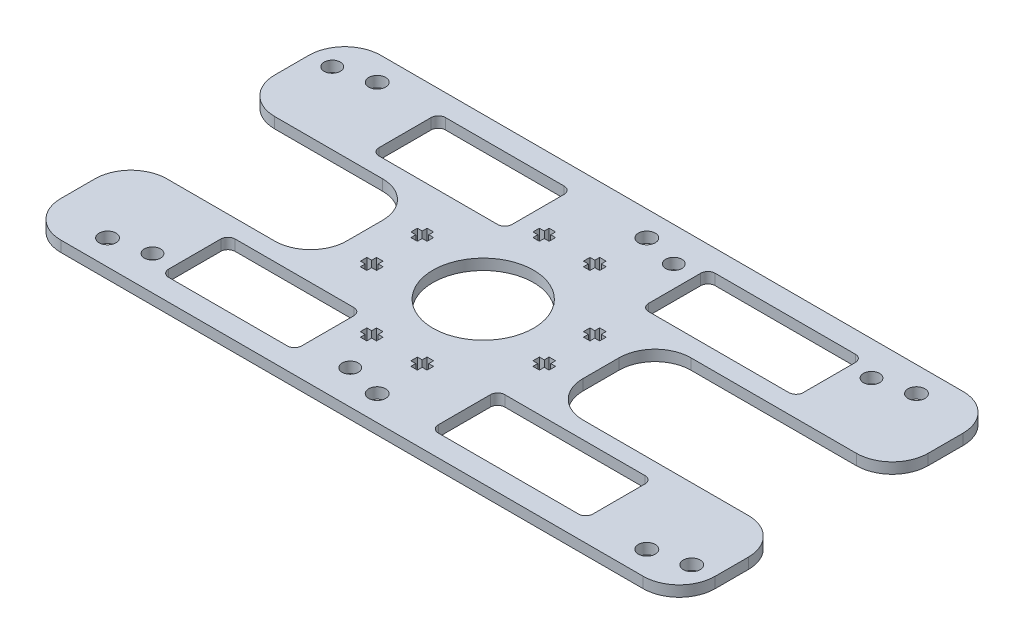
from build123d import *

# Parameters (mm, degrees)
SKETCH1_R           = 14
SKETCH1_R_2         = 2.35
BOSS_EXTRUDE1_DEPTH = 3
CUT_EXTRUDE1_DEPTH  = 104.545719252
FILLET1_R           = 10
SKETCH4_R           = 2.35
SKETCH4_R_2         = 2.25
CUT_EXTRUDE2_DEPTH  = 10
CUT_EXTRUDE3_DEPTH  = 10


with BuildPart() as part:
    # Sketch1 → Boss-Extrude1 (new body)
    with BuildSketch(Plane(origin=(0, 0, 0), x_dir=(1, 0, 0), z_dir=(0, 1, 0))):
        Polygon((24.685193035, -44.266394733), (93.336062351, -44.266394733), (93.336062351, -15), (27.336052671, -15), (27.336052671, 15), (93.336062351, 15), (93.336062351, 44.733605267), (24.683748509, 44.733605267), (-88.663937649, 44.733605267), (-88.663937649, 15.233605267), (-38.663937649, 15.233605267), (-38.663937649, -14.766394733), (-88.663937649, -14.766394733), (-88.663937649, -44.266394733), align=None)
        with Locations((-5.663947329, 0.233605267)):
            Circle(SKETCH1_R, mode=Mode.SUBTRACT)
        with Locations((-72.663947329, -37.266394733)):
            Circle(SKETCH1_R_2, mode=Mode.SUBTRACT)
        with Locations((2.336052671, -37.266394733)):
            Circle(SKETCH1_R_2, mode=Mode.SUBTRACT)
        with Locations((77.336052671, -37.266394733)):
            Circle(SKETCH1_R_2, mode=Mode.SUBTRACT)
        with Locations((77.336052671, 37.733605267)):
            Circle(SKETCH1_R_2, mode=Mode.SUBTRACT)
        with Locations((2.336052671, 37.733605267)):
            Circle(SKETCH1_R_2, mode=Mode.SUBTRACT)
        with Locations((-72.663947329, 37.733605267)):
            Circle(SKETCH1_R_2, mode=Mode.SUBTRACT)
    extrude(amount=BOSS_EXTRUDE1_DEPTH)

    # Sketch3 → Cut-Extrude1 (cut, through all)
    with BuildSketch(Plane(origin=(0, 3, 0), x_dir=(1, 0, 0), z_dir=(0, 1, 0))):
        Polygon((20.586052671, -7.695831984), (20.586052671, -5.895831984), (19.236052671, -5.895831984), (19.236052671, -4.545831984), (17.436052671, -4.545831984), (17.436052671, -5.895831984), (16.086052671, -5.895831984), (16.086052671, -7.695831984), (17.436052671, -7.695831984), (17.436052671, -9.045831984), (19.236052671, -9.045831984), (19.236052671, -7.695831984), align=None)
        Polygon((17.436052671, 5.013042519), (19.236052671, 5.013042519), (19.236052671, 6.363042519), (20.586052671, 6.363042519), (20.586052671, 8.163042519), (19.236052671, 8.163042519), (19.236052671, 9.513042519), (17.436052671, 9.513042519), (17.436052671, 8.163042519), (16.086052671, 8.163042519), (16.086052671, 6.363042519), (17.436052671, 6.363042519), align=None)
        Polygon((-13.59338458, -22.866394733), (-14.94338458, -22.866394733), (-14.94338458, -24.666394733), (-13.59338458, -24.666394733), (-13.59338458, -26.016394733), (-11.79338458, -26.016394733), (-11.79338458, -24.666394733), (-10.44338458, -24.666394733), (-10.44338458, -22.866394733), (-11.79338458, -22.866394733), (-11.79338458, -21.516394733), (-13.59338458, -21.516394733), align=None)
        Polygon((-31.913947329, 8.163042519), (-31.913947329, 6.363042519), (-30.563947329, 6.363042519), (-30.563947329, 5.013042519), (-28.763947329, 5.013042519), (-28.763947329, 6.363042519), (-27.413947329, 6.363042519), (-27.413947329, 8.163042519), (-28.763947329, 8.163042519), (-28.763947329, 9.513042519), (-30.563947329, 9.513042519), (-30.563947329, 8.163042519), align=None)
        Polygon((-0.884510077, -24.666394733), (0.465489923, -24.666394733), (0.465489923, -26.016394733), (2.265489923, -26.016394733), (2.265489923, -24.666394733), (3.615489923, -24.666394733), (3.615489923, -22.866394733), (2.265489923, -22.866394733), (2.265489923, -21.516394733), (0.465489923, -21.516394733), (0.465489923, -22.866394733), (-0.884510077, -22.866394733), align=None)
        Polygon((-31.913947329, -7.695831984), (-30.563947329, -7.695831984), (-30.563947329, -9.045831984), (-28.763947329, -9.045831984), (-28.763947329, -7.695831984), (-27.413947329, -7.695831984), (-27.413947329, -5.895831984), (-28.763947329, -5.895831984), (-28.763947329, -4.545831984), (-30.563947329, -4.545831984), (-30.563947329, -5.895831984), (-31.913947329, -5.895831984), align=None)
        Polygon((0.465489923, 26.483605267), (0.465489923, 25.133605267), (-0.884510077, 25.133605267), (-0.884510077, 23.333605267), (0.465489923, 23.333605267), (0.465489923, 21.983605267), (2.265489923, 21.983605267), (2.265489923, 23.333605267), (3.615489923, 23.333605267), (3.615489923, 25.133605267), (2.265489923, 25.133605267), (2.265489923, 26.483605267), align=None)
        Polygon((-13.59338458, 26.483605267), (-13.59338458, 25.133605267), (-14.94338458, 25.133605267), (-14.94338458, 23.333605267), (-13.59338458, 23.333605267), (-13.59338458, 21.983605267), (-11.79338458, 21.983605267), (-11.79338458, 23.333605267), (-10.44338458, 23.333605267), (-10.44338458, 25.133605267), (-11.79338458, 25.133605267), (-11.79338458, 26.483605267), align=None)
    extrude(amount=-CUT_EXTRUDE1_DEPTH, mode=Mode.SUBTRACT)

    # Fillet1
    fillet1_edges = [part.edges().sort_by_distance(p)[0] for p in [
        (27.336052671, 1.5, 15),
        (27.336052671, 1.5, -15),
        (93.336062351, 1.5, 44.266394733),
        (93.336062351, 1.5, 15),
        (93.336062351, 1.5, -15),
        (93.336062351, 1.5, -44.733605267),
        (-88.663937649, 1.5, 44.266394733),
        (-88.663937649, 1.5, 14.766394733),
        (-38.663937649, 1.5, 14.766394733),
        (-38.663937649, 1.5, -15.233605267),
        (-88.663937649, 1.5, -15.233605267),
        (-88.663937649, 1.5, -44.733605267),
    ]]
    fillet(fillet1_edges, radius=FILLET1_R)

    # Sketch4 → Cut-Extrude2 (cut)
    with BuildSketch(Plane(origin=(0, 3, 0), x_dir=(1, 0, 0), z_dir=(0, 1, 0))):
        with Locations((87.336052671, -34.766394733)):
            Circle(SKETCH4_R)
        with Locations((67.336052671, 35.233605267)):
            Circle(SKETCH4_R_2)
        with Locations((12.336052671, 35.233605267)):
            Circle(SKETCH4_R_2)
        with Locations((-82.663947329, 35.233605267)):
            Circle(SKETCH4_R_2)
        with Locations((-62.663947329, -34.766394733)):
            Circle(SKETCH4_R_2)
        with Locations((-7.663947329, -34.766394733)):
            Circle(SKETCH4_R_2)
    extrude(amount=-CUT_EXTRUDE2_DEPTH, mode=Mode.SUBTRACT)

    # Sketch5 → Cut-Extrude3 (cut)
    with BuildSketch(Plane(origin=(0, 3, 0), x_dir=(1, 0, 0), z_dir=(0, 1, 0))):
        with BuildLine():
            Line((59.336052671, -19.766394733), (20.336052671, -19.766394733))
            ThreePointArc((20.336052671, -19.766394733), (18.921839109, -20.352181171), (18.336052671, -21.766394733))
            Line((18.336052671, -21.766394733), (18.336052671, -36.266394733))
            ThreePointArc((18.336052671, -36.266394733), (18.921839109, -37.680608295), (20.336052671, -38.266394733))
            Line((20.336052671, -38.266394733), (59.336052671, -38.266394733))
            ThreePointArc((59.336052671, -38.266394733), (60.750266234, -37.680608295), (61.336052671, -36.266394733))
            Line((61.336052671, -36.266394733), (61.336052671, -21.766394733))
            ThreePointArc((61.336052671, -21.766394733), (60.750266234, -20.352181171), (59.336052671, -19.766394733))
        make_face()
        with BuildLine():
            Line((18.336052671, 36.733605267), (18.336052671, 22.233605267))
            ThreePointArc((18.336052671, 22.233605267), (18.921839109, 20.819391705), (20.336052671, 20.233605267))
            Line((20.336052671, 20.233605267), (59.336052671, 20.233605267))
            ThreePointArc((59.336052671, 20.233605267), (60.750266234, 20.819391705), (61.336052671, 22.233605267))
            Line((61.336052671, 22.233605267), (61.336052671, 36.733605267))
            ThreePointArc((61.336052671, 36.733605267), (60.750266234, 38.147818829), (59.336052671, 38.733605267))
            Line((59.336052671, 38.733605267), (20.336052671, 38.733605267))
            ThreePointArc((20.336052671, 38.733605267), (18.921839109, 38.147818829), (18.336052671, 36.733605267))
        make_face()
        with BuildLine():
            Line((-56.663947329, -21.766394733), (-56.663947329, -36.266394733))
            ThreePointArc((-56.663947329, -36.266394733), (-56.078160891, -37.680608295), (-54.663947329, -38.266394733))
            Line((-54.663947329, -38.266394733), (-21.663947329, -38.266394733))
            ThreePointArc((-21.663947329, -38.266394733), (-20.249733766, -37.680608295), (-19.663947329, -36.266394733))
            Line((-19.663947329, -36.266394733), (-19.663947329, -21.766394733))
            ThreePointArc((-19.663947329, -21.766394733), (-20.249733766, -20.352181171), (-21.663947329, -19.766394733))
            Line((-21.663947329, -19.766394733), (-54.663947329, -19.766394733))
            ThreePointArc((-54.663947329, -19.766394733), (-56.078160891, -20.352181171), (-56.663947329, -21.766394733))
        make_face()
        with BuildLine():
            Line((-56.663947329, 36.733605267), (-56.663947329, 22.233605267))
            ThreePointArc((-56.663947329, 22.233605267), (-56.078160891, 20.819391705), (-54.663947329, 20.233605267))
            Line((-54.663947329, 20.233605267), (-21.663947329, 20.233605267))
            ThreePointArc((-21.663947329, 20.233605267), (-20.249733766, 20.819391705), (-19.663947329, 22.233605267))
            Line((-19.663947329, 22.233605267), (-19.663947329, 36.733605267))
            ThreePointArc((-19.663947329, 36.733605267), (-20.249733766, 38.147818829), (-21.663947329, 38.733605267))
            Line((-21.663947329, 38.733605267), (-54.663947329, 38.733605267))
            ThreePointArc((-54.663947329, 38.733605267), (-56.078160891, 38.147818829), (-56.663947329, 36.733605267))
        make_face()
    extrude(amount=-CUT_EXTRUDE3_DEPTH, mode=Mode.SUBTRACT)


solid = part.part
